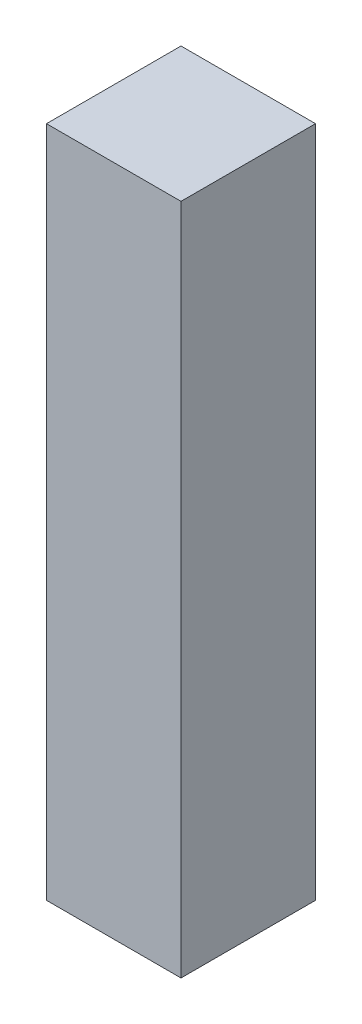
from build123d import *

# Parameters (mm, degrees)
SKETCH1_W           = 20
SKETCH1_H           = 20
BOSS_EXTRUDE1_DEPTH = 100


with BuildPart() as part:
    # Sketch1 → Boss-Extrude1 (new body)
    with BuildSketch(Plane(origin=(0, 0, 0), x_dir=(1, 0, 0), z_dir=(0, 1, 0))):
        with Locations((-0.2, -1.45)):
            Rectangle(SKETCH1_W, SKETCH1_H)
    extrude(amount=BOSS_EXTRUDE1_DEPTH)


solid = part.part
